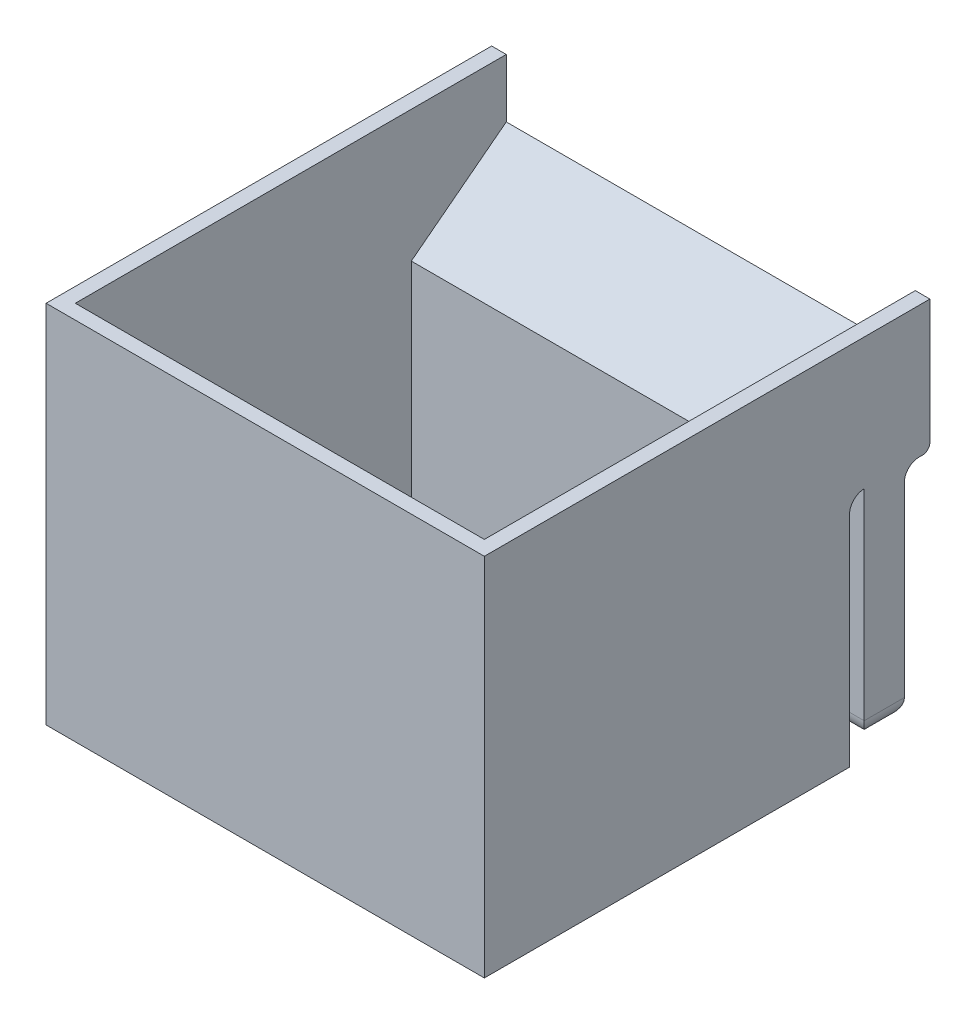
from build123d import *

# Parameters (mm, degrees)
EXTRUDE_1_DEPTH = 60
FILLET_1_R      = 2
SKETCH_2_W      = 60
SKETCH_2_H      = 5.5
EXTRUDE_2_DEPTH = 30
FILLET_3_R      = 2
SKETCH_3_W      = 2
SKETCH_3_H      = 46
EXTRUDE_3_DEPTH = 48
SKETCH_4_W      = 2
SKETCH_4_H      = 18
EXTRUDE_4_DEPTH = 13
SKETCH_5_W      = 2
SKETCH_5_H      = 18
EXTRUDE_5_DEPTH = 13
FILLET_4_R      = 1
FILLET_5_R      = 2.5


with BuildPart() as part:
    # 草圖1 → 填料-伸長1 (new body)
    with BuildSketch(Plane(origin=(0, 0, 0), x_dir=(0, 0, -1), z_dir=(1, 0, 0))):
        Polygon((-42.254416961, 29.533568905), (-42.254416961, -20.466431095), (7.745583039, -20.466431095), (7.745583039, 11.533568905), (18.745583039, 11.533568905), (18.745583039, 21.533568905), (5.745583039, 11.533568905), (5.745583039, -18.466431095), (-40.254416961, -18.466431095), (-40.254416961, 29.533568905), align=None)
    extrude(amount=EXTRUDE_1_DEPTH)

    # 圓角1
    fillet_1_edges = [part.edges().sort_by_distance(p)[0] for p in [
        (30, 11.533568905, -7.745583039),
    ]]
    fillet(fillet_1_edges, radius=FILLET_1_R)

    # 草圖2 → 填料-伸長2 (add)
    with BuildSketch(Plane.XZ.offset(-11.533568905)):
        with Locations((30, -12.495583039)):
            Rectangle(SKETCH_2_W, SKETCH_2_H)
    extrude(amount=EXTRUDE_2_DEPTH)

    # 圓角3
    fillet_3_edges = [part.edges().sort_by_distance(p)[0] for p in [
        (30, 11.533568905, -15.245583039),
    ]]
    fillet(fillet_3_edges, radius=FILLET_3_R)

    # 草圖3 → 填料-伸長3 (add)
    with BuildSketch(Plane(origin=(0, -18.466431095, 0), x_dir=(1, 0, 0), z_dir=(0, 1, 0))):
        with Locations((1, -17.254416961)):
            Rectangle(SKETCH_3_W, SKETCH_3_H)
        with Locations((59, -17.254416961)):
            Rectangle(SKETCH_3_W, SKETCH_3_H)
    extrude(amount=EXTRUDE_3_DEPTH)

    # 草圖4 → 填料-伸長4 (add)
    with BuildSketch(Plane(origin=(0, 0, -5.745583039), x_dir=(-1, 0, 0), z_dir=(0, 0, -1))):
        with Locations((-1, 20.533568905)):
            Rectangle(SKETCH_4_W, SKETCH_4_H)
    extrude(amount=EXTRUDE_4_DEPTH)

    # 草圖5 → 填料-伸長5 (add)
    with BuildSketch(Plane(origin=(0, 0, -5.745583039), x_dir=(-1, 0, 0), z_dir=(0, 0, -1))):
        with Locations((-59, 20.533568905)):
            Rectangle(SKETCH_5_W, SKETCH_5_H)
    extrude(amount=EXTRUDE_5_DEPTH)

    # 圓角4
    fillet_4_edges = [part.edges().sort_by_distance(p)[0] for p in [
        (30, 11.533568905, -18.745583039),
    ]]
    fillet(fillet_4_edges, radius=FILLET_4_R)

    # 圓角5
    fillet_5_edges = [part.edges().sort_by_distance(p)[0] for p in [
        (60, -18.466431095, -12.495583039),
        (30, -18.466431095, -9.745583039),
        (30, -18.466431095, -15.245583039),
        (0, -18.466431095, -12.495583039),
    ]]
    fillet(fillet_5_edges, radius=FILLET_5_R)


solid = part.part
